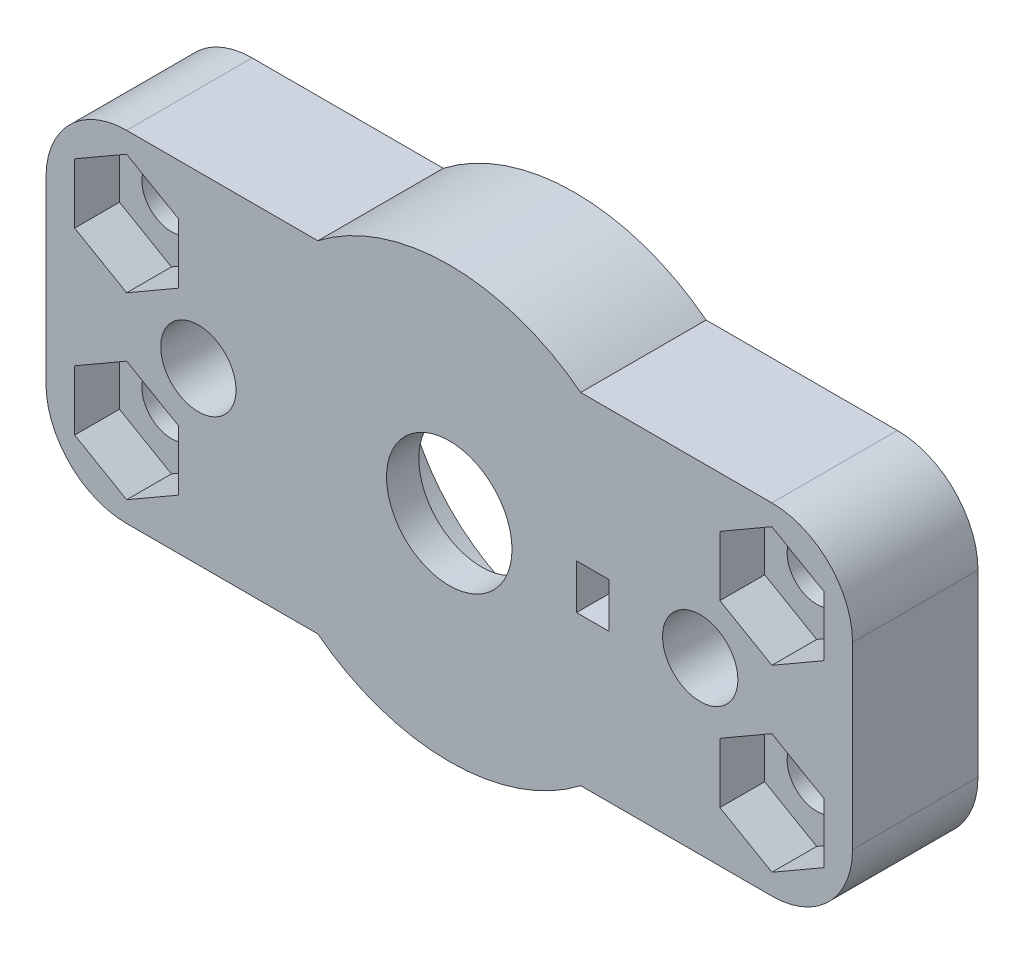
from build123d import *

# Parameters (mm, degrees)
SKETCH2_R           = 1.65
BOSS_EXTRUDE1_DEPTH = 7
SKETCH3_R           = 9.7
CUT_EXTRUDE1_DEPTH  = 5
SKETCH4_R           = 7.5
CUT_EXTRUDE2_DEPTH  = 5
CUT_EXTRUDE3_DEPTH  = 2.5
SKETCH6_R           = 7.5
SKETCH6_R_2         = 3.5
BOSS_EXTRUDE2_DEPTH = 1.8
SKETCH7_W           = 1.8
SKETCH7_H           = 2.5
CUT_EXTRUDE4_DEPTH  = 2.5
SKETCH8_R           = 2.1
CUT_EXTRUDE5_DEPTH  = 3


with BuildPart() as part:
    # Sketch2 → Boss-Extrude1 (new body)
    with BuildSketch(Plane.XY):
        with BuildLine():
            Line((-18, 9.5), (-7.331439149, 9.5))
            ThreePointArc((-7.331439149, 9.5), (0, 12), (7.331439149, 9.5))
            Line((7.331439149, 9.5), (18, 9.5))
            ThreePointArc((18, 9.5), (21.181980515, 8.181980515), (22.5, 5))
            Line((22.5, 5), (22.5, -5))
            ThreePointArc((22.5, -5), (21.181980515, -8.181980515), (18, -9.5))
            Line((18, -9.5), (7.331439149, -9.5))
            ThreePointArc((7.331439149, -9.5), (0, -12), (-7.331439149, -9.5))
            Line((-7.331439149, -9.5), (-18, -9.5))
            ThreePointArc((-18, -9.5), (-21.181980515, -8.181980515), (-22.5, -5))
            Line((-22.5, -5), (-22.5, 5))
            ThreePointArc((-22.5, 5), (-21.181980515, 8.181980515), (-18, 9.5))
        make_face()
        with Locations((-18, 5)):
            Circle(SKETCH2_R, mode=Mode.SUBTRACT)
        with Locations((18, 5)):
            Circle(SKETCH2_R, mode=Mode.SUBTRACT)
        with Locations((18, -5)):
            Circle(SKETCH2_R, mode=Mode.SUBTRACT)
        with Locations((-18, -5)):
            Circle(SKETCH2_R, mode=Mode.SUBTRACT)
    extrude(amount=BOSS_EXTRUDE1_DEPTH)

    # Sketch3 → Cut-Extrude1 (cut)
    with BuildSketch(Plane.XY):
        Circle(SKETCH3_R)
    extrude(amount=CUT_EXTRUDE1_DEPTH, mode=Mode.SUBTRACT)

    # Sketch4 → Cut-Extrude2 (cut)
    with BuildSketch(Plane(origin=(0, 0, 5), x_dir=(-1, 0, 0), z_dir=(0, 0, -1))):
        Circle(SKETCH4_R)
    extrude(amount=-CUT_EXTRUDE2_DEPTH, mode=Mode.SUBTRACT)

    # Sketch5 → Cut-Extrude3 (cut)
    with BuildSketch(Plane.XY.offset(7)):
        Polygon((-18, 8.348631561), (-20.9, 6.674315781), (-20.9, 3.325684219), (-18, 1.651368439), (-15.1, 3.325684219), (-15.1, 6.674315781), align=None)
        Polygon((15.1, 6.674315781), (18, 8.348631561), (20.9, 6.674315781), (20.9, 3.325684219), (18, 1.651368439), (15.1, 3.325684219), align=None)
        Polygon((15.1, -3.325684219), (15.1, -6.674315781), (18, -8.348631561), (20.9, -6.674315781), (20.9, -3.325684219), (18, -1.651368439), align=None)
        Polygon((-15.1, -6.674315781), (-18, -8.348631561), (-20.9, -6.674315781), (-20.9, -3.325684219), (-18, -1.651368439), (-15.1, -3.325684219), align=None)
    extrude(amount=-CUT_EXTRUDE3_DEPTH, mode=Mode.SUBTRACT)

    # Sketch6 → Boss-Extrude2 (add)
    with BuildSketch(Plane.XY.offset(7)):
        Circle(SKETCH6_R)
        Circle(SKETCH6_R_2, mode=Mode.SUBTRACT)
    extrude(amount=-BOSS_EXTRUDE2_DEPTH)

    # Sketch7 → Cut-Extrude4 (cut)
    with BuildSketch(Plane.XY.offset(7)):
        with Locations((8, 0)):
            Rectangle(SKETCH7_W, SKETCH7_H)
    extrude(amount=-CUT_EXTRUDE4_DEPTH, mode=Mode.SUBTRACT)

    # Sketch8 → Cut-Extrude5 (cut)
    with BuildSketch(Plane.XY.offset(7)):
        with Locations((-14, 0)):
            Circle(SKETCH8_R)
        with Locations((14, 0)):
            Circle(SKETCH8_R)
    extrude(amount=-CUT_EXTRUDE5_DEPTH, mode=Mode.SUBTRACT)


solid = part.part
